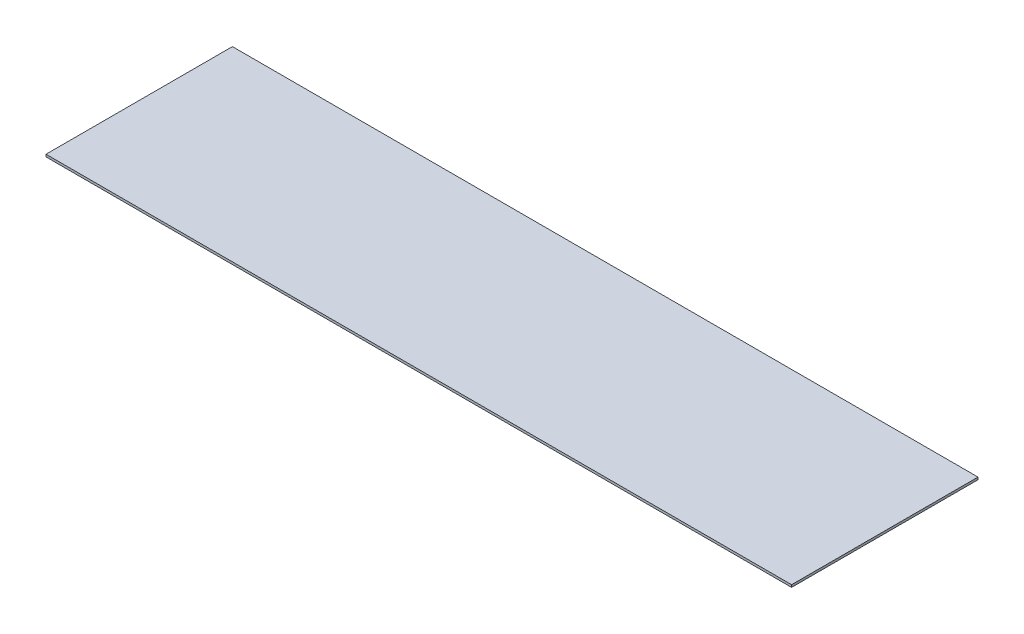
from build123d import *

# Parameters (mm, degrees)
SKETCH1_W           = 508
SKETCH1_H           = 127
BOSS_EXTRUDE1_DEPTH = 1.6


with BuildPart() as part:
    # Sketch1 → Boss-Extrude1 (new body)
    with BuildSketch(Plane(origin=(0, 0, 0), x_dir=(1, 0, 0), z_dir=(0, 1, 0))):
        with Locations((254, 63.5)):
            Rectangle(SKETCH1_W, SKETCH1_H)
    extrude(amount=BOSS_EXTRUDE1_DEPTH)


solid = part.part
